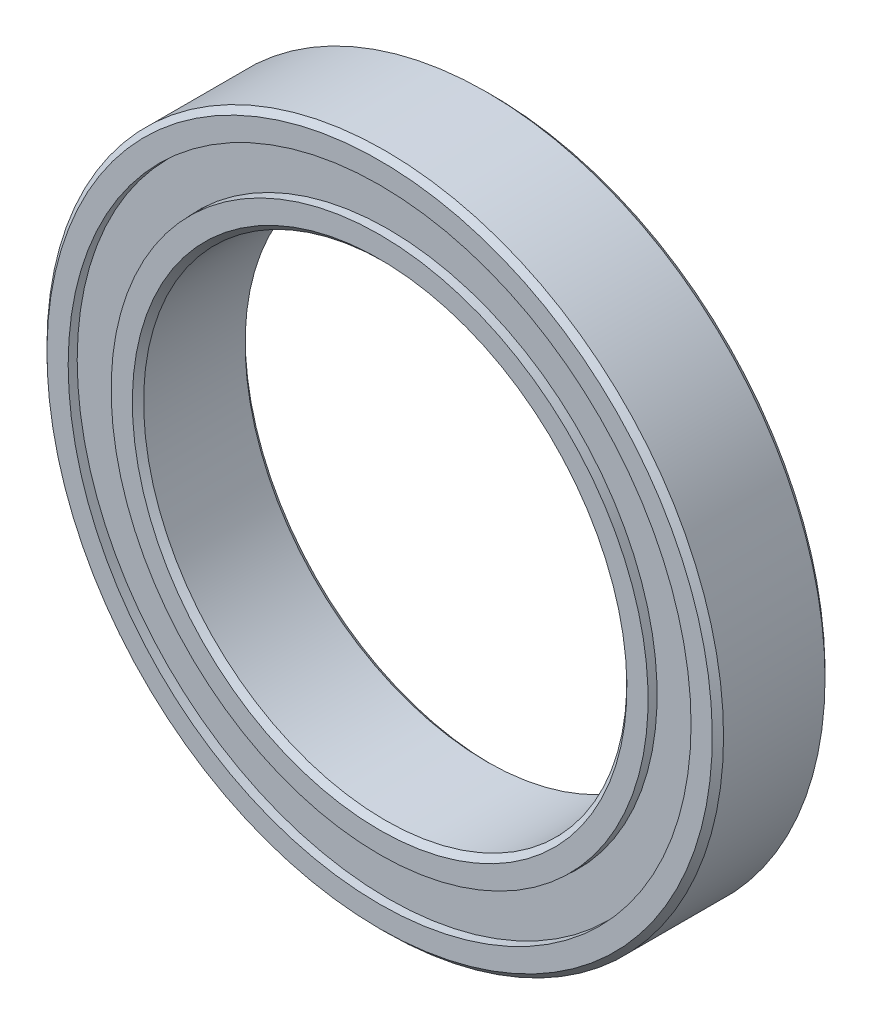
from build123d import *

# Parameters (mm, degrees)
SKETCH5_W         = 0.381
SKETCH5_H         = 2.615866666
CIRPATTERN1_COUNT = 17


with BuildPart() as part:
    # Sketch5 → Revolve1 (revolve)
    with BuildSketch(Plane(origin=(0, 0, 0), x_dir=(0, 0, -1), z_dir=(1, 0, 0))):
        with BuildLine():
            Line((3.15, 21), (-3.15, 21))
            Line((-3.15, 21), (-3.5, 20.65))
            Line((-3.5, 20.65), (-3.5, 19.333333333))
            Line((-3.5, 19.333333333), (-1.555555556, 19.333333333))
            ThreePointArc((-1.555555556, 19.333333333), (0, 20.048787657), (1.555555556, 19.333333333))
            Line((1.555555556, 19.333333333), (3.5, 19.333333333))
            Line((3.5, 19.333333333), (3.5, 20.65))
            Line((3.5, 20.65), (3.15, 21))
        make_face()
        with Locations((2.774393829, 18)):
            Rectangle(SKETCH5_W, SKETCH5_H)
        with Locations((-2.774393829, 18)):
            Rectangle(SKETCH5_W, SKETCH5_H)
    revolve(axis=Axis((0, 0, 3.5), (0, 0, -1)))


with BuildPart() as body_2:
    # Sketch3 → Revolve3 (revolve)
    with BuildSketch(Plane(origin=(0, 0, 0), x_dir=(0, 0, -1), z_dir=(1, 0, 0))):
        with BuildLine():
            Line((-3.5, 16.666666667), (-1.555555556, 16.666666667))
            ThreePointArc((-1.555555556, 16.666666667), (0, 15.951212343), (1.555555556, 16.666666667))
            Line((1.555555556, 16.666666667), (3.5, 16.666666667))
            Line((3.5, 16.666666667), (3.5, 15.35))
            Line((3.5, 15.35), (3.15, 15))
            Line((3.15, 15), (-3.15, 15))
            Line((-3.15, 15), (-3.5, 15.35))
            Line((-3.5, 15.35), (-3.5, 16.666666667))
        make_face()
    revolve(axis=Axis((0, 0, 3.5), (0, 0, -1)))


with BuildPart() as body_3:
    # Sketch4 → Revolve4 (revolve)
    with BuildSketch(Plane(origin=(0, 0, 0), x_dir=(0, 0, -1), z_dir=(1, 0, 0))):
        with BuildLine():
            Line((-2.048787657, 18), (2.048787657, 18))
            ThreePointArc((2.048787657, 18), (0, 20.048787657), (-2.048787657, 18))
        make_face()
    revolve(axis=Axis((0, 18, 2.048787657), (0, 0, -1)))


with BuildPart() as cirpattern1_1:
    # CirPattern1: pattern copy
    add(body_3.part.rotate(Axis((0, 0, 0), (0, 0, 1)), 1 * 360 / CIRPATTERN1_COUNT))


with BuildPart() as cirpattern1_2:
    # CirPattern1: pattern copy
    add(body_3.part.rotate(Axis((0, 0, 0), (0, 0, 1)), 2 * 360 / CIRPATTERN1_COUNT))


with BuildPart() as cirpattern1_3:
    # CirPattern1: pattern copy
    add(body_3.part.rotate(Axis((0, 0, 0), (0, 0, 1)), 3 * 360 / CIRPATTERN1_COUNT))


with BuildPart() as cirpattern1_4:
    # CirPattern1: pattern copy
    add(body_3.part.rotate(Axis((0, 0, 0), (0, 0, 1)), 4 * 360 / CIRPATTERN1_COUNT))


with BuildPart() as cirpattern1_5:
    # CirPattern1: pattern copy
    add(body_3.part.rotate(Axis((0, 0, 0), (0, 0, 1)), 5 * 360 / CIRPATTERN1_COUNT))


with BuildPart() as cirpattern1_6:
    # CirPattern1: pattern copy
    add(body_3.part.rotate(Axis((0, 0, 0), (0, 0, 1)), 6 * 360 / CIRPATTERN1_COUNT))


with BuildPart() as cirpattern1_7:
    # CirPattern1: pattern copy
    add(body_3.part.rotate(Axis((0, 0, 0), (0, 0, 1)), 7 * 360 / CIRPATTERN1_COUNT))


with BuildPart() as cirpattern1_8:
    # CirPattern1: pattern copy
    add(body_3.part.rotate(Axis((0, 0, 0), (0, 0, 1)), 8 * 360 / CIRPATTERN1_COUNT))


with BuildPart() as cirpattern1_9:
    # CirPattern1: pattern copy
    add(body_3.part.rotate(Axis((0, 0, 0), (0, 0, 1)), 9 * 360 / CIRPATTERN1_COUNT))


with BuildPart() as cirpattern1_10:
    # CirPattern1: pattern copy
    add(body_3.part.rotate(Axis((0, 0, 0), (0, 0, 1)), 10 * 360 / CIRPATTERN1_COUNT))


with BuildPart() as cirpattern1_11:
    # CirPattern1: pattern copy
    add(body_3.part.rotate(Axis((0, 0, 0), (0, 0, 1)), 11 * 360 / CIRPATTERN1_COUNT))


with BuildPart() as cirpattern1_12:
    # CirPattern1: pattern copy
    add(body_3.part.rotate(Axis((0, 0, 0), (0, 0, 1)), 12 * 360 / CIRPATTERN1_COUNT))


with BuildPart() as cirpattern1_13:
    # CirPattern1: pattern copy
    add(body_3.part.rotate(Axis((0, 0, 0), (0, 0, 1)), 13 * 360 / CIRPATTERN1_COUNT))


with BuildPart() as cirpattern1_14:
    # CirPattern1: pattern copy
    add(body_3.part.rotate(Axis((0, 0, 0), (0, 0, 1)), 14 * 360 / CIRPATTERN1_COUNT))


with BuildPart() as cirpattern1_15:
    # CirPattern1: pattern copy
    add(body_3.part.rotate(Axis((0, 0, 0), (0, 0, 1)), 15 * 360 / CIRPATTERN1_COUNT))


with BuildPart() as cirpattern1_16:
    # CirPattern1: pattern copy
    add(body_3.part.rotate(Axis((0, 0, 0), (0, 0, 1)), 16 * 360 / CIRPATTERN1_COUNT))


solid = Compound([part.part, body_2.part, body_3.part, cirpattern1_1.part, cirpattern1_2.part, cirpattern1_3.part, cirpattern1_4.part, cirpattern1_5.part, cirpattern1_6.part, cirpattern1_7.part, cirpattern1_8.part, cirpattern1_9.part, cirpattern1_10.part, cirpattern1_11.part, cirpattern1_12.part, cirpattern1_13.part, cirpattern1_14.part, cirpattern1_15.part, cirpattern1_16.part])
